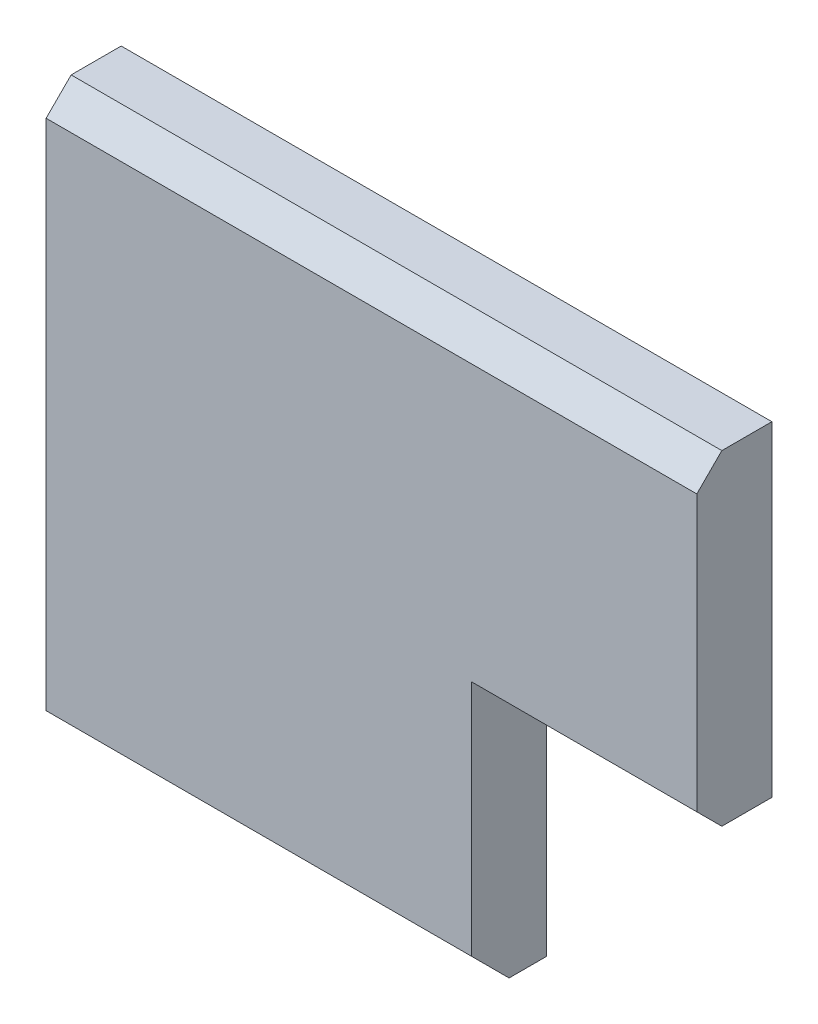
from build123d import *

# Parameters (mm, degrees)
SKETCH_1_W          = 26
SKETCH_1_H          = 23
EXTRUDE_1_DEPTH     = 3
CHAMFER_1_SIZE      = 1.5
CUT_EXTRUDE_1_DEPTH = 4
CHAMFER_2_SIZE      = 1


with BuildPart() as part:
    # Эскиз1 → Вытянуть1 (new body)
    with BuildSketch(Plane.XY):
        with Locations((0, 1.5)):
            Rectangle(SKETCH_1_W, SKETCH_1_H)
    extrude(amount=EXTRUDE_1_DEPTH)

    # Фаска1
    chamfer_1_edges = [part.edges().sort_by_distance(p)[0] for p in [
        (0, -10, 3),
    ]]
    chamfer(chamfer_1_edges, length=CHAMFER_1_SIZE)

    # Эскиз2 → Вырез-Вытянуть1 (cut, through all)
    with BuildSketch(Plane(origin=(0, 0, 0), x_dir=(-1, 0, 0), z_dir=(0, 0, -1))):
        Polygon((-81.137767415, 0), (-13, 0), (-4, 0), (-4, -10), (-4, -78.137767415), (-100.979926637, -173.876553822), (-178.117694052, -95.738786407), align=None)
    extrude(amount=-CUT_EXTRUDE_1_DEPTH, mode=Mode.SUBTRACT)

    # Фаска2
    chamfer_2_edges = [part.edges().sort_by_distance(p)[0] for p in [
        (0, 13, 3),
        (8.5, 0, 3),
    ]]
    chamfer(chamfer_2_edges, length=CHAMFER_2_SIZE)


solid = part.part
